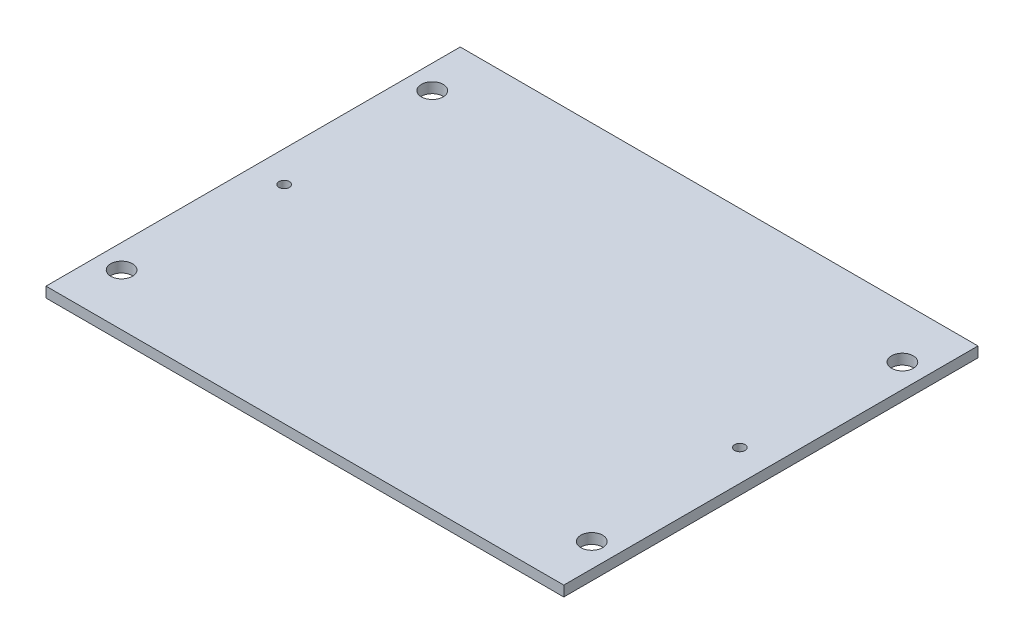
from build123d import *

# Parameters (mm, degrees)
SKETCH1_W           = 500
SKETCH1_H           = 400
SKETCH1_R           = 10.5
SKETCH1_R_2         = 5
BOSS_EXTRUDE1_DEPTH = 10


with BuildPart() as part:
    # Sketch1 → Boss-Extrude1 (new body)
    with BuildSketch(Plane(origin=(0, 0, 0), x_dir=(1, 0, 0), z_dir=(0, 1, 0))):
        Rectangle(SKETCH1_W, SKETCH1_H)
        with Locations((-227, 150)):
            Circle(SKETCH1_R, mode=Mode.SUBTRACT)
        with Locations((-227, -150)):
            Circle(SKETCH1_R, mode=Mode.SUBTRACT)
        with Locations((227, -150)):
            Circle(SKETCH1_R, mode=Mode.SUBTRACT)
        with Locations((227, 150)):
            Circle(SKETCH1_R, mode=Mode.SUBTRACT)
        with Locations((-220, 0)):
            Circle(SKETCH1_R_2, mode=Mode.SUBTRACT)
        with Locations((220, 0)):
            Circle(SKETCH1_R_2, mode=Mode.SUBTRACT)
    extrude(amount=BOSS_EXTRUDE1_DEPTH)


solid = part.part
